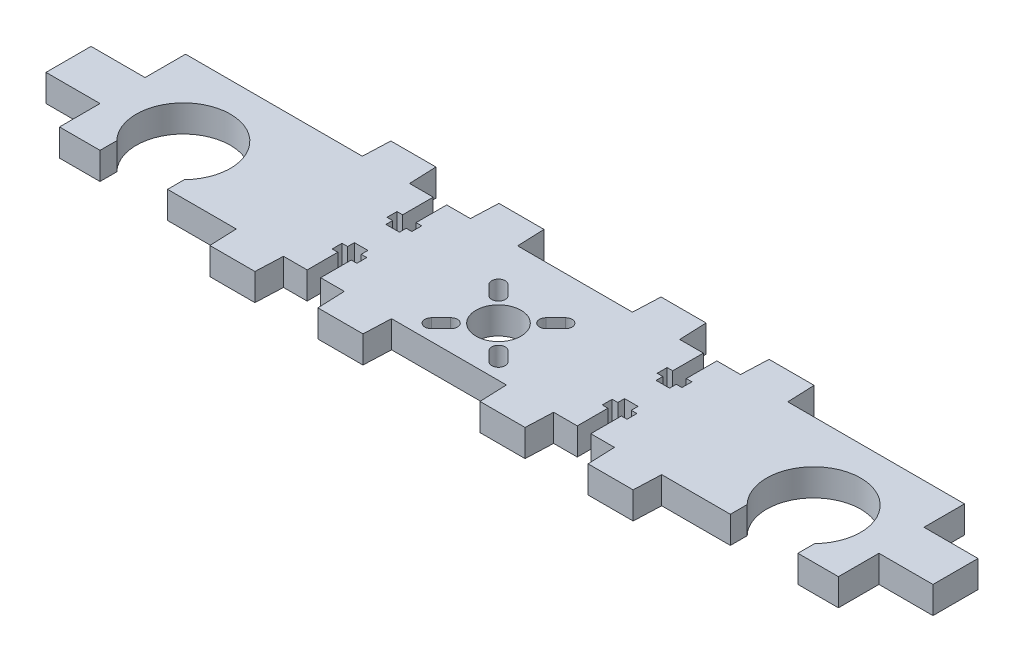
from build123d import *

# Parameters (mm, degrees)
SKETCH_1_R      = 5
EXTRUDE_1_DEPTH = 6


with BuildPart() as part:
    # Эскиз1 → Бобышка-Вытянуть1 (new body)
    with BuildSketch(Plane(origin=(0, 0, 0), x_dir=(1, 0, 0), z_dir=(0, 1, 0))):
        with BuildLine():
            Line((86.763576424, -13.868211788), (86.763576424, -4.868211788))
            Line((86.763576424, -4.868211788), (98.763576424, -4.868211788))
            Line((98.763576424, -4.868211788), (98.763576424, 5.131788212))
            Line((98.763576424, 5.131788212), (86.763576424, 5.131788212))
            Line((86.763576424, 5.131788212), (86.763576424, 14.131788212))
            Line((86.763576424, 14.131788212), (47.513576424, 14.131788212))
            Line((47.513576424, 14.131788212), (47.263576424, 20.231788212))
            Line((47.263576424, 20.231788212), (37.263576424, 20.231788212))
            Line((37.263576424, 20.231788212), (37.013576424, 14.131788212))
            Line((37.013576424, 14.131788212), (31.763576424, 14.131788212))
            Line((31.763576424, 14.131788212), (31.763576424, 7.331788212))
            Line((31.763576424, 7.331788212), (33.013576424, 7.331788212))
            Line((33.013576424, 7.331788212), (33.013576424, 5.131788212))
            Line((33.013576424, 5.131788212), (31.763576424, 5.131788212))
            Line((31.763576424, 5.131788212), (31.763576424, 3.631788212))
            Line((31.763576424, 3.631788212), (28.763576424, 3.631788212))
            Line((28.763576424, 3.631788212), (28.763576424, 5.131788212))
            Line((28.763576424, 5.131788212), (27.513576424, 5.131788212))
            Line((27.513576424, 5.131788212), (27.513576424, 7.331788212))
            Line((27.513576424, 7.331788212), (28.763576424, 7.331788212))
            Line((28.763576424, 7.331788212), (28.763576424, 14.131788212))
            Line((28.763576424, 14.131788212), (23.513576424, 14.131788212))
            Line((23.513576424, 14.131788212), (23.263576424, 20.231788212))
            Line((23.263576424, 20.231788212), (13.263576424, 20.231788212))
            Line((13.263576424, 20.231788212), (13.013576424, 14.131788212))
            Line((13.013576424, 14.131788212), (-12.486423576, 14.131788212))
            Line((-12.486423576, 14.131788212), (-12.736423576, 20.231788212))
            Line((-12.736423576, 20.231788212), (-22.736423576, 20.231788212))
            Line((-22.736423576, 20.231788212), (-22.986423576, 14.131788212))
            Line((-22.986423576, 14.131788212), (-28.236423576, 14.131788212))
            Line((-28.236423576, 14.131788212), (-28.236423576, 7.331788212))
            Line((-28.236423576, 7.331788212), (-26.986423576, 7.331788212))
            Line((-26.986423576, 7.331788212), (-26.986423576, 5.131788212))
            Line((-26.986423576, 5.131788212), (-28.236423576, 5.131788212))
            Line((-28.236423576, 5.131788212), (-28.236423576, 3.631788212))
            Line((-28.236423576, 3.631788212), (-31.236423576, 3.631788212))
            Line((-31.236423576, 3.631788212), (-31.236423576, 5.131788212))
            Line((-31.236423576, 5.131788212), (-32.486423576, 5.131788212))
            Line((-32.486423576, 5.131788212), (-32.486423576, 7.331788212))
            Line((-32.486423576, 7.331788212), (-31.236423576, 7.331788212))
            Line((-31.236423576, 7.331788212), (-31.236423576, 14.131788212))
            Line((-31.236423576, 14.131788212), (-36.486423576, 14.131788212))
            Line((-36.486423576, 14.131788212), (-36.736423576, 20.231788212))
            Line((-36.736423576, 20.231788212), (-46.736423576, 20.231788212))
            Line((-46.736423576, 20.231788212), (-46.986423576, 14.131788212))
            Line((-46.986423576, 14.131788212), (-86.236423576, 14.131788212))
            Line((-86.236423576, 14.131788212), (-86.236423576, 5.131788212))
            Line((-86.236423576, 5.131788212), (-98.236423576, 5.131788212))
            Line((-98.236423576, 5.131788212), (-98.236423576, -4.868211788))
            Line((-98.236423576, -4.868211788), (-86.236423576, -4.868211788))
            Line((-86.236423576, -4.868211788), (-86.236423576, -13.868211788))
            Line((-86.236423576, -13.868211788), (-77.236423576, -13.868211788))
            Line((-77.236423576, -13.868211788), (-77.236423576, -10.145058633))
            ThreePointArc((-77.236423576, -10.145058633), (-69.736423576, 7.581788212), (-62.236423576, -10.145058633))
            Line((-62.236423576, -10.145058633), (-62.236423576, -13.868211788))
            Line((-62.236423576, -13.868211788), (-46.986423576, -13.868211788))
            Line((-46.986423576, -13.868211788), (-46.736423576, -19.968211788))
            Line((-46.736423576, -19.968211788), (-36.736423576, -19.968211788))
            Line((-36.736423576, -19.968211788), (-36.486423576, -13.868211788))
            Line((-36.486423576, -13.868211788), (-31.236423576, -13.868211788))
            Line((-31.236423576, -13.868211788), (-31.236423576, -7.068211788))
            Line((-31.236423576, -7.068211788), (-32.486423576, -7.068211788))
            Line((-32.486423576, -7.068211788), (-32.486423576, -4.868211788))
            Line((-32.486423576, -4.868211788), (-31.236423576, -4.868211788))
            Line((-31.236423576, -4.868211788), (-31.236423576, -3.368211788))
            Line((-31.236423576, -3.368211788), (-28.236423576, -3.368211788))
            Line((-28.236423576, -3.368211788), (-28.236423576, -4.868211788))
            Line((-28.236423576, -4.868211788), (-26.986423576, -4.868211788))
            Line((-26.986423576, -4.868211788), (-26.986423576, -7.068211788))
            Line((-26.986423576, -7.068211788), (-28.236423576, -7.068211788))
            Line((-28.236423576, -7.068211788), (-28.236423576, -13.868211788))
            Line((-28.236423576, -13.868211788), (-22.986423576, -13.868211788))
            Line((-22.986423576, -13.868211788), (-22.736423576, -19.968211788))
            Line((-22.736423576, -19.968211788), (-12.736423576, -19.968211788))
            Line((-12.736423576, -19.968211788), (-12.486423576, -13.868211788))
            Line((-12.486423576, -13.868211788), (13.013576424, -13.868211788))
            Line((13.013576424, -13.868211788), (13.263576424, -19.968211788))
            Line((13.263576424, -19.968211788), (23.263576424, -19.968211788))
            Line((23.263576424, -19.968211788), (23.513576424, -13.868211788))
            Line((23.513576424, -13.868211788), (28.763576424, -13.868211788))
            Line((28.763576424, -13.868211788), (28.763576424, -7.068211788))
            Line((28.763576424, -7.068211788), (27.513576424, -7.068211788))
            Line((27.513576424, -7.068211788), (27.513576424, -4.868211788))
            Line((27.513576424, -4.868211788), (28.763576424, -4.868211788))
            Line((28.763576424, -4.868211788), (28.763576424, -3.368211788))
            Line((28.763576424, -3.368211788), (31.763576424, -3.368211788))
            Line((31.763576424, -3.368211788), (31.763576424, -4.868211788))
            Line((31.763576424, -4.868211788), (33.013576424, -4.868211788))
            Line((33.013576424, -4.868211788), (33.013576424, -7.068211788))
            Line((33.013576424, -7.068211788), (31.763576424, -7.068211788))
            Line((31.763576424, -7.068211788), (31.763576424, -13.868211788))
            Line((31.763576424, -13.868211788), (37.013576424, -13.868211788))
            Line((37.013576424, -13.868211788), (37.263576424, -19.968211788))
            Line((37.263576424, -19.968211788), (47.263576424, -19.968211788))
            Line((47.263576424, -19.968211788), (47.513576424, -13.868211788))
            Line((47.513576424, -13.868211788), (62.763576424, -13.868211788))
            Line((62.763576424, -13.868211788), (62.763576424, -10.145058633))
            ThreePointArc((62.763576424, -10.145058633), (70.263576424, 7.581788212), (77.763576424, -10.145058633))
            Line((77.763576424, -10.145058633), (77.763576424, -13.868211788))
            Line((77.763576424, -13.868211788), (86.763576424, -13.868211788))
        make_face()
        with Locations((0.263576424, -2.868211788)):
            Circle(SKETCH_1_R, mode=Mode.SUBTRACT)
        with BuildLine():
            Line((-8.221704951, -9.232172819), (-6.100384607, -7.110852475))
            ThreePointArc((-6.100384607, -7.110852475), (-3.979064264, -7.110852475), (-3.979064264, -9.232172819))
            Line((-3.979064264, -9.232172819), (-6.100384607, -11.353493162))
            ThreePointArc((-6.100384607, -11.353493162), (-8.221704951, -11.353493162), (-8.221704951, -9.232172819))
        make_face(mode=Mode.SUBTRACT)
        with BuildLine():
            Line((-6.100384607, 5.617069586), (-3.979064264, 3.495749242))
            ThreePointArc((-3.979064264, 3.495749242), (-3.979064264, 1.374428899), (-6.100384607, 1.374428899))
            Line((-6.100384607, 1.374428899), (-8.221704951, 3.495749242))
            ThreePointArc((-8.221704951, 3.495749242), (-8.221704951, 5.617069586), (-6.100384607, 5.617069586))
        make_face(mode=Mode.SUBTRACT)
        with BuildLine():
            Line((8.748857798, -9.232172819), (6.627537454, -7.110852475))
            ThreePointArc((6.627537454, -7.110852475), (4.506217111, -7.110852475), (4.506217111, -9.232172819))
            Line((4.506217111, -9.232172819), (6.627537454, -11.353493162))
            ThreePointArc((6.627537454, -11.353493162), (8.748857798, -11.353493162), (8.748857798, -9.232172819))
        make_face(mode=Mode.SUBTRACT)
        with BuildLine():
            Line((6.627537454, 5.617069586), (4.506217111, 3.495749242))
            ThreePointArc((4.506217111, 3.495749242), (4.506217111, 1.374428899), (6.627537454, 1.374428899))
            Line((6.627537454, 1.374428899), (8.748857798, 3.495749243))
            ThreePointArc((8.748857798, 3.495749243), (8.748857798, 5.617069586), (6.627537454, 5.617069586))
        make_face(mode=Mode.SUBTRACT)
    extrude(amount=EXTRUDE_1_DEPTH)


solid = part.part
